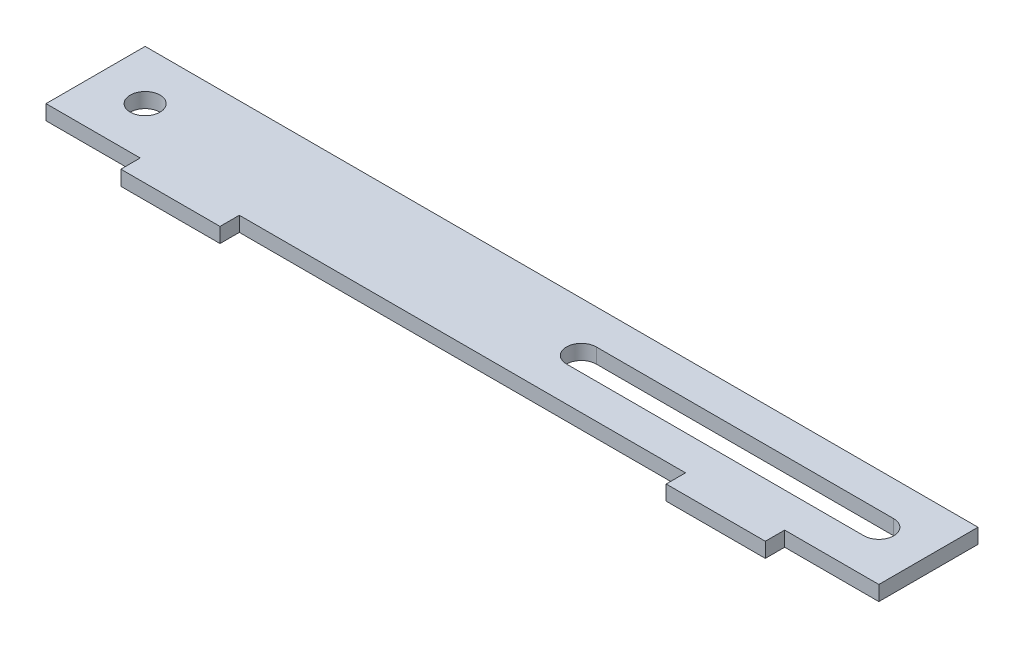
from build123d import *

# Parameters (mm, degrees)
SKETCH1_R           = 3
BOSS_EXTRUDE1_DEPTH = 3


with BuildPart() as part:
    # Sketch1 → Boss-Extrude1 (new body)
    with BuildSketch(Plane(origin=(0, 0, 0), x_dir=(1, 0, 0), z_dir=(0, 1, 0))):
        Polygon((0, 0), (19, 0), (19, -3.9), (39, -3.9), (39, 0), (129, 0), (129, -3.9), (149, -3.9), (149, 0), (168, 0), (168, 20), (0, 20), align=None)
        with Locations((10, 10)):
            Circle(SKETCH1_R, mode=Mode.SUBTRACT)
        with BuildLine():
            Line((158, 7), (98, 7))
            ThreePointArc((98, 7), (95, 10), (98, 13))
            Line((98, 13), (158, 13))
            ThreePointArc((158, 13), (161, 10), (158, 7))
        make_face(mode=Mode.SUBTRACT)
    extrude(amount=BOSS_EXTRUDE1_DEPTH)


solid = part.part
